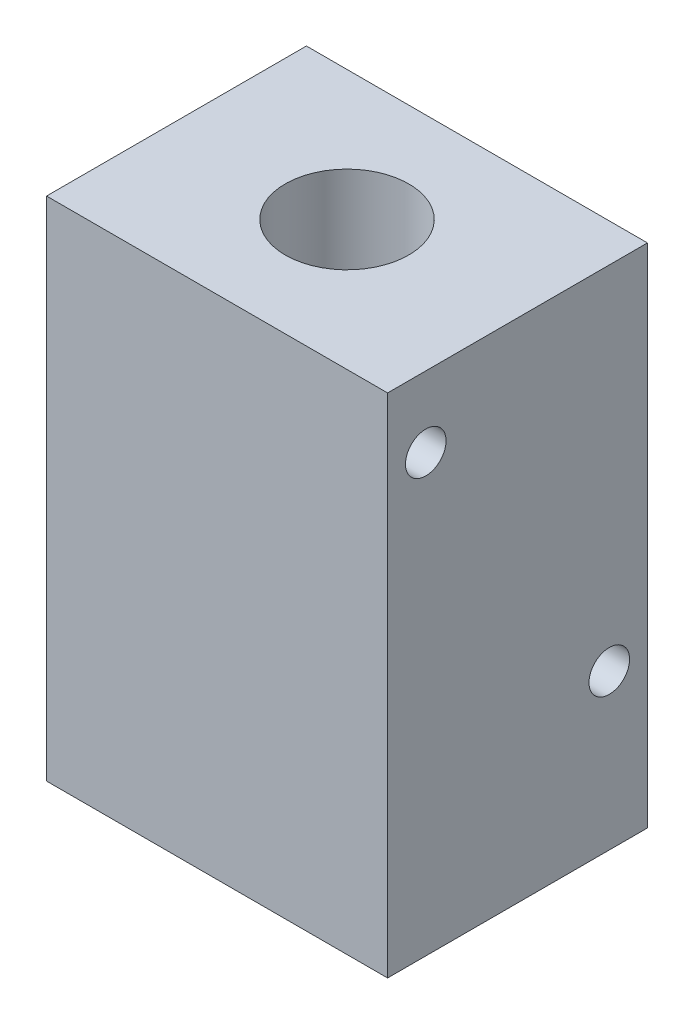
from build123d import *

# Parameters (mm, degrees)
SKETCH1_W           = 26.67
SKETCH1_H           = 20.32
BOSS_EXTRUDE1_DEPTH = 39.624
SKETCH2_R           = 2.413
CUT_EXTRUDE1_DEPTH  = 40.624
SKETCH3_R           = 4.826
CUT_EXTRUDE2_DEPTH  = 28.448
SKETCH4_R           = 1.5875
CUT_EXTRUDE3_DEPTH  = 2.54


with BuildPart() as part:
    # Sketch1 → Boss-Extrude1 (new body)
    with BuildSketch(Plane(origin=(0, 0, 0), x_dir=(1, 0, 0), z_dir=(0, 1, 0))):
        with Locations((13.335, 10.16)):
            Rectangle(SKETCH1_W, SKETCH1_H)
    extrude(amount=BOSS_EXTRUDE1_DEPTH)

    # Sketch2 → Cut-Extrude1 (cut, through all)
    with BuildSketch(Plane.XZ):
        with Locations((13.335, -10.16)):
            Circle(SKETCH2_R)
    extrude(amount=-CUT_EXTRUDE1_DEPTH, mode=Mode.SUBTRACT)

    # Sketch3 → Cut-Extrude2 (cut)
    with BuildSketch(Plane(origin=(0, 39.624, 0), x_dir=(1, 0, 0), z_dir=(0, 1, 0))):
        with Locations((13.335, 10.16)):
            Circle(SKETCH3_R)
    extrude(amount=-CUT_EXTRUDE2_DEPTH, mode=Mode.SUBTRACT)

    # Sketch4 → Cut-Extrude3 (cut)
    with BuildSketch(Plane(origin=(26.67, 0, 0), x_dir=(0, 0, -1), z_dir=(1, 0, 0))):
        with Locations((2.9845, 34.0995)):
            Circle(SKETCH4_R)
        with Locations((17.3355, 12.1285)):
            Circle(SKETCH4_R)
    extrude(amount=-CUT_EXTRUDE3_DEPTH, mode=Mode.SUBTRACT)


solid = part.part
